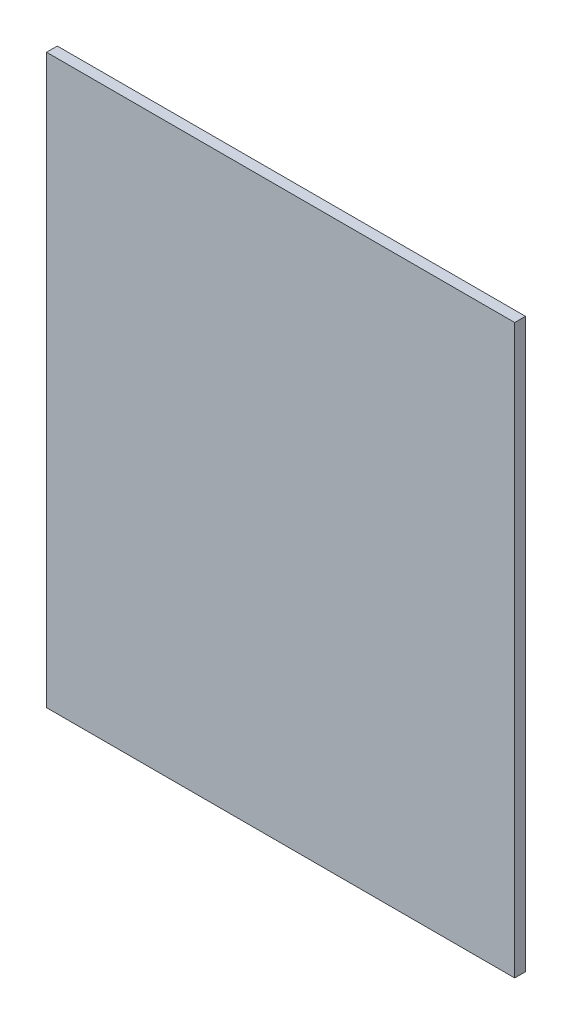
from build123d import *

# Parameters (mm, degrees)
SKETCH1_W           = 174.064160833
SKETCH1_H           = 211.04739762
BOSS_EXTRUDE1_DEPTH = 4


with BuildPart() as part:
    # Sketch1 → Boss-Extrude1 (new body)
    with BuildSketch(Plane.XY):
        with Locations((-42.234880602, -320.561484724)):
            Rectangle(SKETCH1_W, SKETCH1_H)
    extrude(amount=BOSS_EXTRUDE1_DEPTH)


solid = part.part
